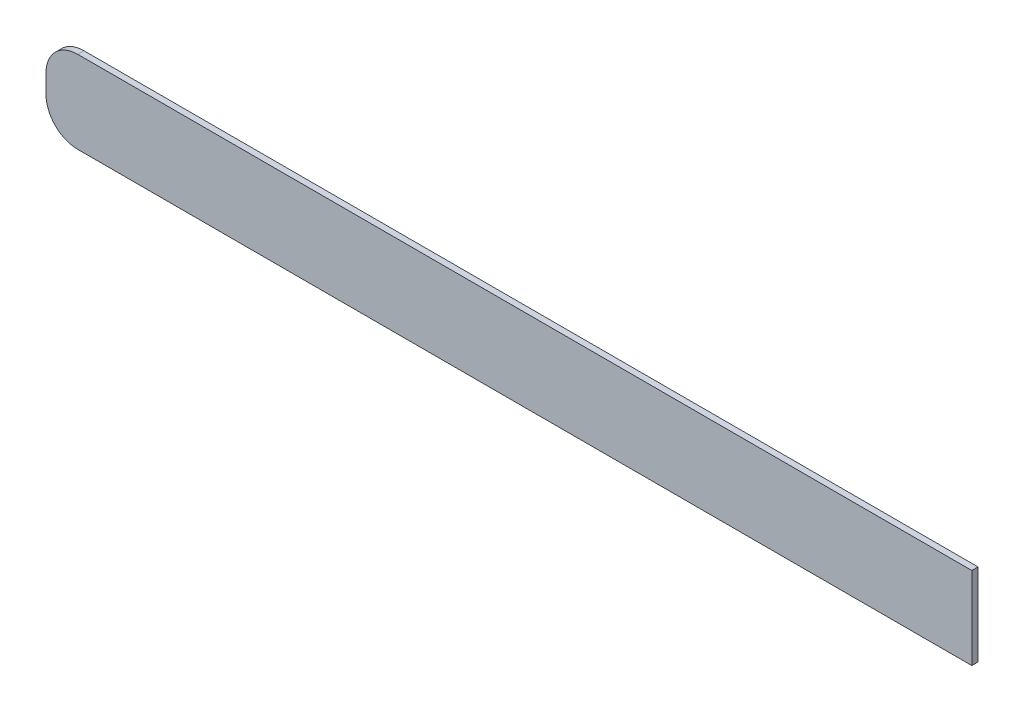
from build123d import *

# Parameters (mm, degrees)
BOSS_EXTRUDE1_DEPTH = 0.4953


with BuildPart() as part:
    # Sketch1 → Boss-Extrude1 (new body)
    with BuildSketch(Plane.XY):
        with BuildLine():
            Line((36.9824, -3.2893), (-34.4424, -3.2893))
            ThreePointArc((-34.4424, -3.2893), (-36.238451224, -2.545351224), (-36.9824, -0.7493))
            Line((-36.9824, -0.7493), (-36.9824, 0.7493))
            ThreePointArc((-36.9824, 0.7493), (-36.238451224, 2.545351224), (-34.4424, 3.2893))
            Line((-34.4424, 3.2893), (36.9824, 3.2893))
            Line((36.9824, 3.2893), (36.9824, -3.2893))
        make_face()
    extrude(amount=BOSS_EXTRUDE1_DEPTH)


solid = part.part
